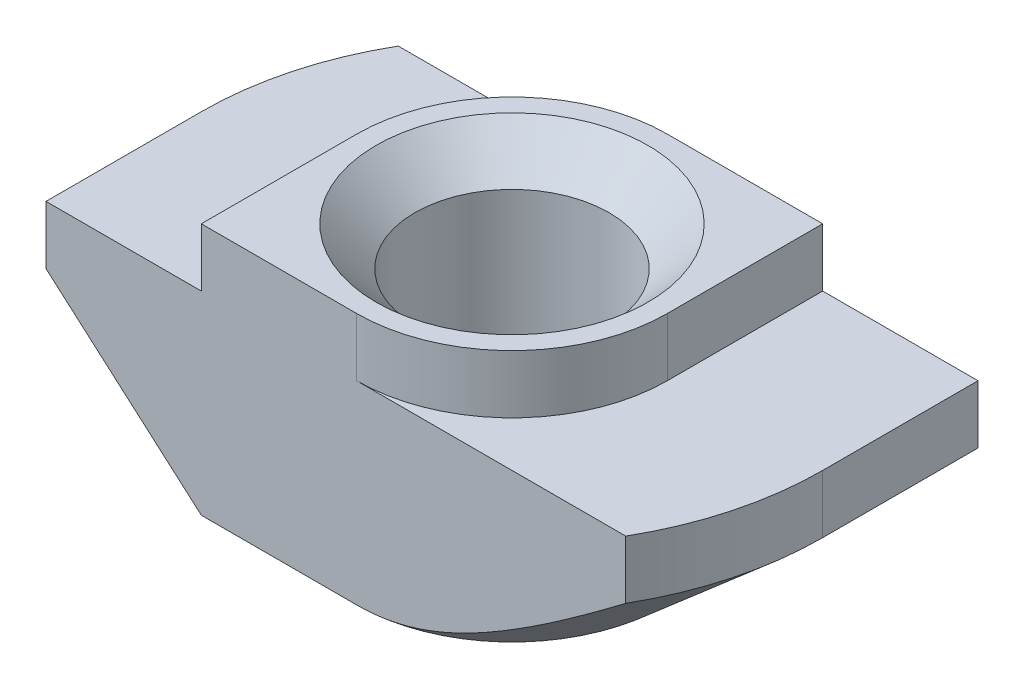
from build123d import *

# Parameters (mm, degrees)
EXTRUDE_1_DEPTH     = 4
CUT_EXTRUDE_1_DEPTH = 1.5
CUT_EXTRUDE_2_DEPTH = 6


with BuildPart() as part:
    # Эскиз1 → Бобышка-Вытянуть1 (new body, symmetric)
    with BuildSketch(Plane.XY):
        Polygon((4, 0), (-4, 0), (-4, -1.5), (-8, -1.5), (-8, -6.5), (8, -6.5), (8, -1.5), (4, -1.5), align=None)
    extrude(amount=EXTRUDE_1_DEPTH, both=True)

    # Эскиз3 → Отверстие обработанное метчиком M61 (revolve, cut)
    with BuildSketch(Plane(origin=(0, 0, 0), x_dir=(0, 0, 1), z_dir=(1, 0, 0))):
        Polygon((0, 0), (0, 6.5), (3.5, 6.5), (2.5, 5.5), (2.5, 1), (3.5, 0), align=None)
    revolve(axis=Axis((0, 6.35, 0), (0, -1, 0)), mode=Mode.SUBTRACT)

    # Эскиз4 → Вырез-Вытянуть1 (cut)
    with BuildSketch(Plane(origin=(0, 0, 0), x_dir=(1, 0, 0), z_dir=(0, 1, 0))):
        with BuildLine():
            Line((-4, 4), (-4, 0))
            ThreePointArc((-4, 0), (-2.828427125, 2.828427125), (0, 4))
            Line((0, 4), (-4, 4))
        make_face()
        with BuildLine():
            Line((0, -4), (4, -4))
            Line((4, -4), (4, 0))
            ThreePointArc((4, 0), (2.828427125, -2.828427125), (0, -4))
        make_face()
    extrude(amount=-CUT_EXTRUDE_1_DEPTH, mode=Mode.SUBTRACT)

    # Эскиз5 → Вырез-Вытянуть2 (cut, through all)
    with BuildSketch(Plane(origin=(0, -1.5, 0), x_dir=(1, 0, 0), z_dir=(0, 1, 0))):
        with BuildLine():
            Line((-8, 0), (-8, 4))
            Line((-8, 4), (-6.92820323, 4))
            ThreePointArc((-6.92820323, 4), (-7.72740661, 2.070552361), (-8, 0))
        make_face()
        with BuildLine():
            Line((8, 0), (8, -4))
            Line((8, -4), (6.92820323, -4))
            ThreePointArc((6.92820323, -4), (7.72740661, -2.070552361), (8, 0))
        make_face()
    extrude(amount=-CUT_EXTRUDE_2_DEPTH, mode=Mode.SUBTRACT)

    # Вырез-По траектории1: sweep along a path in Эскиз7
    with BuildLine(Plane.XZ.offset(6.5)) as sweep_1_path:
        Line((0, 8), (-8, 8))
        Line((-8, 8), (-8, 0))
        ThreePointArc((-8, 0), (-5.656854249, -5.656854249), (0, -8))
        Line((0, -8), (8, -8))
        Line((8, -8), (8, 0))
        ThreePointArc((8, 0), (5.656854249, 5.656854249), (0, 8))
    # Эскиз6 → Вырез-По траектории1 (sweep, cut)
    with BuildSketch(Plane.XY.offset(4)):
        Polygon((-8, -3), (-8, -6.5), (-4, -6.5), align=None)
    sweep(path=sweep_1_path.line, transition=Transition.RIGHT, mode=Mode.SUBTRACT)


solid = part.part
